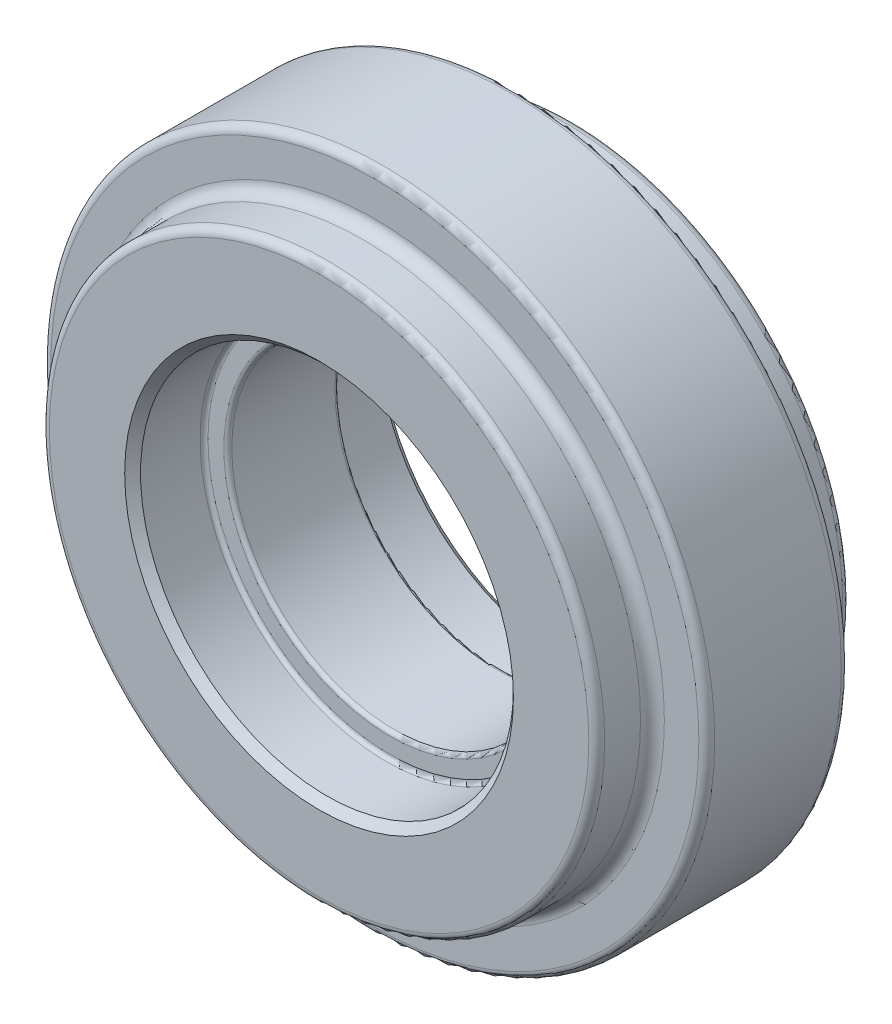
from build123d import *

# Parameters (mm, degrees)
SKETCH_1_R          = 41.84762
EXTRUDE_1_DEPTH     = 17.955
SKETCH_2_R          = 35
EXTRUDE_2_DEPTH     = 7.0225
SKETCH_3_R          = 35
EXTRUDE_3_DEPTH     = 7.0225
FILLET_1_R          = 1.5
FILLET_2_R          = 1
SKETCH_4_R          = 23.5
CUT_EXTRUDE_1_DEPTH = 9
SKETCH_5_R          = 23.5
CUT_EXTRUDE_2_DEPTH = 9
CUT_EXTRUDE_3_REACH = 25
SKETCH_6_R          = 20.5
FILLET_3_R          = 0.5
CHAMFER_1_SIZE      = 1


with BuildPart() as part:
    # 草图1 → 凸台-拉伸1 (new body)
    with BuildSketch(Plane.XY):
        Circle(SKETCH_1_R)
    extrude(amount=EXTRUDE_1_DEPTH)

    # 草图2 → 凸台-拉伸2 (add)
    with BuildSketch(Plane.XY.offset(17.955)):
        Circle(SKETCH_2_R)
    extrude(amount=EXTRUDE_2_DEPTH)

    # 草图3 → 凸台-拉伸3 (add)
    with BuildSketch(Plane(origin=(0, 0, 0), x_dir=(-1, 0, 0), z_dir=(0, 0, -1))):
        Circle(SKETCH_3_R)
    extrude(amount=EXTRUDE_3_DEPTH)

    # 圆角1
    fillet_1_edges = [part.edges().sort_by_distance(p)[0] for p in [
        (-35, 0, 17.955),
        (35, 0, 0),
    ]]
    fillet(fillet_1_edges, radius=FILLET_1_R)

    # 圆角2
    fillet_2_edges = [part.edges().sort_by_distance(p)[0] for p in [
        (35, 0, -7.0225),
        (-41.84762, 0, 0),
        (-41.84762, 0, 17.955),
        (-35, 0, 24.9775),
    ]]
    fillet(fillet_2_edges, radius=FILLET_2_R)

    # 草图4 → 切除-拉伸1 (cut)
    with BuildSketch(Plane.XY.offset(24.9775)):
        Circle(SKETCH_4_R)
    extrude(amount=-CUT_EXTRUDE_1_DEPTH, mode=Mode.SUBTRACT)

    # 草图5 → 切除-拉伸2 (cut)
    with BuildSketch(Plane(origin=(0, 0, -7.0225), x_dir=(-1, 0, 0), z_dir=(0, 0, -1))):
        Circle(SKETCH_5_R)
    extrude(amount=-CUT_EXTRUDE_2_DEPTH, mode=Mode.SUBTRACT)

    # 草图6 → 切除-拉伸3 (cut, up to next)
    with BuildSketch(Plane(origin=(0, 0, 1.9775), x_dir=(-1, 0, 0), z_dir=(0, 0, -1)), mode=Mode.PRIVATE) as cut_extrude_3_sk1:
        Circle(SKETCH_6_R)
    cut_extrude_3_tool1 = extrude(cut_extrude_3_sk1.sketch, amount=-CUT_EXTRUDE_3_REACH, mode=Mode.PRIVATE) & part.part
    add(cut_extrude_3_tool1.solids().sort_by_distance((0, 0, 1.9775))[0], mode=Mode.SUBTRACT)

    # 圆角3
    fillet_3_edges = [part.edges().sort_by_distance(p)[0] for p in [
        (-23.5, 0, 15.9775),
        (23.5, 0, 1.9775),
        (20.5, 0, 15.9775),
        (20.5, 0, 1.9775),
    ]]
    fillet(fillet_3_edges, radius=FILLET_3_R)

    # 倒角1
    chamfer_1_edges = [part.edges().sort_by_distance(p)[0] for p in [
        (-23.5, 0, 24.9775),
        (23.5, 0, -7.0225),
    ]]
    chamfer(chamfer_1_edges, length=CHAMFER_1_SIZE)


solid = part.part
